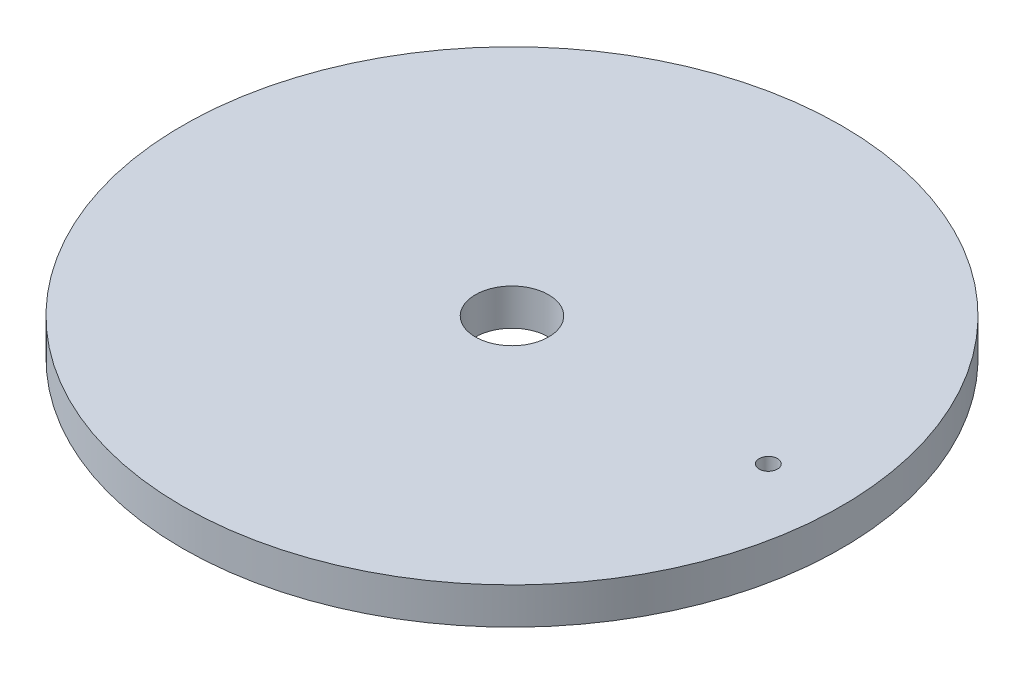
from build123d import *

# Parameters (mm, degrees)
F_1_8_0_125_DIAMETER_HOLE1_D     = 3.175
F_1_8_0_125_DIAMETER_HOLE1_DEPTH = 3.302
F_1_8_0_125_DIAMETER_HOLE1_TIP   = 0.953866233


with BuildPart() as part:
    # Sketch1 → Revolve1 (revolve)
    with BuildSketch(Plane.XY):
        Polygon((-6.35, 0), (-52.5145, 0), (-52.5145, 2.032), (-55.5625, 2.032), (-55.5625, 0), (-57.15, 0), (-57.15, 6.35), (-6.35, 6.35), align=None)
    revolve(axis=Axis((0, 0, 0), (0, 1, 0)))

    # 1/8 (0.125) Diameter Hole1
    with Locations(Plane(origin=(0, 6.35, 0), x_dir=(1, 0, 0), z_dir=(0, 1, 0))):
        with Locations((44.45, 0)):
            Hole(F_1_8_0_125_DIAMETER_HOLE1_D / 2, depth=F_1_8_0_125_DIAMETER_HOLE1_DEPTH)
            with Locations((0, 0, -(F_1_8_0_125_DIAMETER_HOLE1_DEPTH + F_1_8_0_125_DIAMETER_HOLE1_TIP / 2))):  # 118° drill point
                Cone(0, F_1_8_0_125_DIAMETER_HOLE1_D / 2, F_1_8_0_125_DIAMETER_HOLE1_TIP, mode=Mode.SUBTRACT)


solid = part.part
